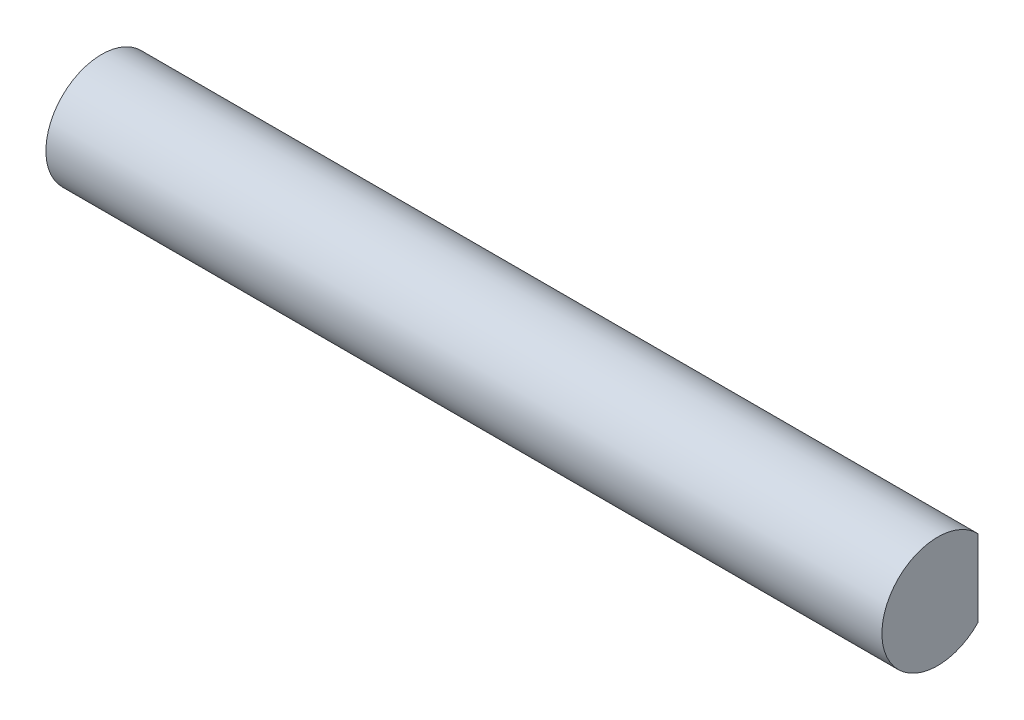
from build123d import *

# Parameters (mm, degrees)
BAR_DEPTH           = 150
CUT_EXTRUDE4_DEPTH  = 5
CUT_EXTRUDE3_REACH  = 19.238
SKETCH6_W           = 48.933333333
SKETCH6_H           = 12.2
SKETCH6_W_2         = 48.933333334
BOSS_EXTRUDE2_DEPTH = 0.8


with BuildPart() as part:
    # Sketch1 → Bar (new body)
    with BuildSketch(Plane(origin=(0, 0, 0), x_dir=(0, 0, -1), z_dir=(1, 0, 0))):
        with BuildLine():
            Line((7.238093672, -6.9), (7.238093672, 6.9))
            ThreePointArc((7.238093672, 6.9), (-10, 0), (7.238093672, -6.9))
        make_face()
        Polygon((1, 6.573205081), (-1.005255888, 7.730940108), (-4.9, 5.482308546), (-4.9, -5.482308546), (-1.005255888, -7.730940108), (1, -6.573205081), align=None, mode=Mode.SUBTRACT)
    extrude(amount=-BAR_DEPTH)

    # Sketch10 → Cut-Extrude4 (cut)
    with BuildSketch(Plane.ZY.offset(150)):
        with BuildLine():
            Line((-6.238093672, -6.487386788), (-6.238093672, 6.487386788))
            ThreePointArc((-6.238093672, 6.487386788), (9, 0), (-6.238093672, -6.487386788))
        make_face()
    extrude(amount=-CUT_EXTRUDE4_DEPTH, mode=Mode.SUBTRACT)

    # Sketch6 → Cut-Extrude3 (cut, up to next)
    with BuildSketch(Plane(origin=(0, 0, -7.238093672), x_dir=(1, 0, 0), z_dir=(0, 0, -1)), mode=Mode.PRIVATE) as cut_extrude3_sk1:
        with Locations((-25.266666667, 0)):
            Rectangle(SKETCH6_W, SKETCH6_H)
    cut_extrude3_tool1 = extrude(cut_extrude3_sk1.sketch, amount=-CUT_EXTRUDE3_REACH, mode=Mode.PRIVATE) & part.part
    add(cut_extrude3_tool1.solids().sort_by_distance((-25.266667, 0, -7.238094))[0], mode=Mode.SUBTRACT)
    # Sketch6 → Cut-Extrude3 (cut, up to next)
    with BuildSketch(Plane(origin=(0, 0, -7.238093672), x_dir=(1, 0, 0), z_dir=(0, 0, -1)), mode=Mode.PRIVATE) as cut_extrude3_sk2:
        with Locations((-75, 0)):
            Rectangle(SKETCH6_W_2, SKETCH6_H)
    cut_extrude3_tool2 = extrude(cut_extrude3_sk2.sketch, amount=-CUT_EXTRUDE3_REACH, mode=Mode.PRIVATE) & part.part
    add(cut_extrude3_tool2.solids().sort_by_distance((-75, 0, -7.238094))[0], mode=Mode.SUBTRACT)
    # Sketch6 → Cut-Extrude3 (cut, up to next)
    with BuildSketch(Plane(origin=(0, 0, -7.238093672), x_dir=(1, 0, 0), z_dir=(0, 0, -1)), mode=Mode.PRIVATE) as cut_extrude3_sk3:
        with Locations((-124.733333334, 0)):
            Rectangle(SKETCH6_W, SKETCH6_H)
    cut_extrude3_tool3 = extrude(cut_extrude3_sk3.sketch, amount=-CUT_EXTRUDE3_REACH, mode=Mode.PRIVATE) & part.part
    add(cut_extrude3_tool3.solids().sort_by_distance((-124.733333, 0, -7.238094))[0], mode=Mode.SUBTRACT)

    # Sketch11 → Boss-Extrude2 (add)
    with BuildSketch(Plane(origin=(0, 0, 0), x_dir=(0, 0, -1), z_dir=(1, 0, 0))):
        with BuildLine():
            Line((7.238093672, -6.9), (7.238093672, 6.9))
            ThreePointArc((7.238093672, 6.9), (-10, 0), (7.238093672, -6.9))
        make_face()
    extrude(amount=-BOSS_EXTRUDE2_DEPTH)


solid = part.part
